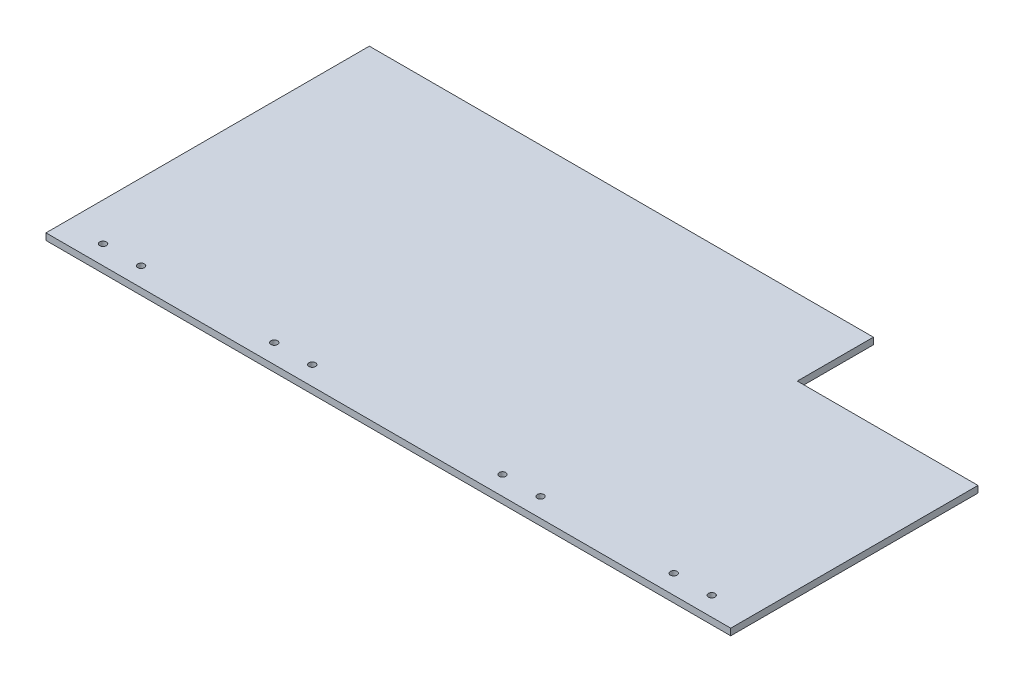
from build123d import *

# Parameters (mm, degrees)
SKETCH1_W           = 360
SKETCH1_H           = 170
BOSS_EXTRUDE1_DEPTH = 3.5
SKETCH2_R           = 1.75
CUT_EXTRUDE1_DEPTH  = 3.5
CUT_EXTRUDE2_REACH  = 5.5
SKETCH3_W           = 95
SKETCH3_H           = 40


with BuildPart() as part:
    # Sketch1 → Boss-Extrude1 (new body)
    with BuildSketch(Plane(origin=(0, 0, 0), x_dir=(1, 0, 0), z_dir=(0, 1, 0))):
        with Locations((180, 85)):
            Rectangle(SKETCH1_W, SKETCH1_H)
    extrude(amount=BOSS_EXTRUDE1_DEPTH)

    # Sketch2 → Cut-Extrude1 (cut)
    with BuildSketch(Plane(origin=(0, 3.5, 0), x_dir=(1, 0, 0), z_dir=(0, 1, 0))):
        with Locations((20, 10)):
            Circle(SKETCH2_R)
        with Locations((40, 10)):
            Circle(SKETCH2_R)
        with Locations((110, 10)):
            Circle(SKETCH2_R)
        with Locations((130, 10)):
            Circle(SKETCH2_R)
        with Locations((230, 10)):
            Circle(SKETCH2_R)
        with Locations((250, 10)):
            Circle(SKETCH2_R)
        with Locations((320, 10)):
            Circle(SKETCH2_R)
        with Locations((340, 10)):
            Circle(SKETCH2_R)
    extrude(amount=-CUT_EXTRUDE1_DEPTH, mode=Mode.SUBTRACT)

    # Sketch3 → Cut-Extrude2 (cut, up to next)
    with BuildSketch(Plane(origin=(0, 3.5, 0), x_dir=(1, 0, 0), z_dir=(0, 1, 0)), mode=Mode.PRIVATE) as cut_extrude2_sk1:
        with Locations((312.5, 150)):
            Rectangle(SKETCH3_W, SKETCH3_H)
    cut_extrude2_tool1 = extrude(cut_extrude2_sk1.sketch, amount=-CUT_EXTRUDE2_REACH, mode=Mode.PRIVATE) & part.part
    add(cut_extrude2_tool1.solids().sort_by_distance((312.5, 3.5, -150))[0], mode=Mode.SUBTRACT)


solid = part.part
